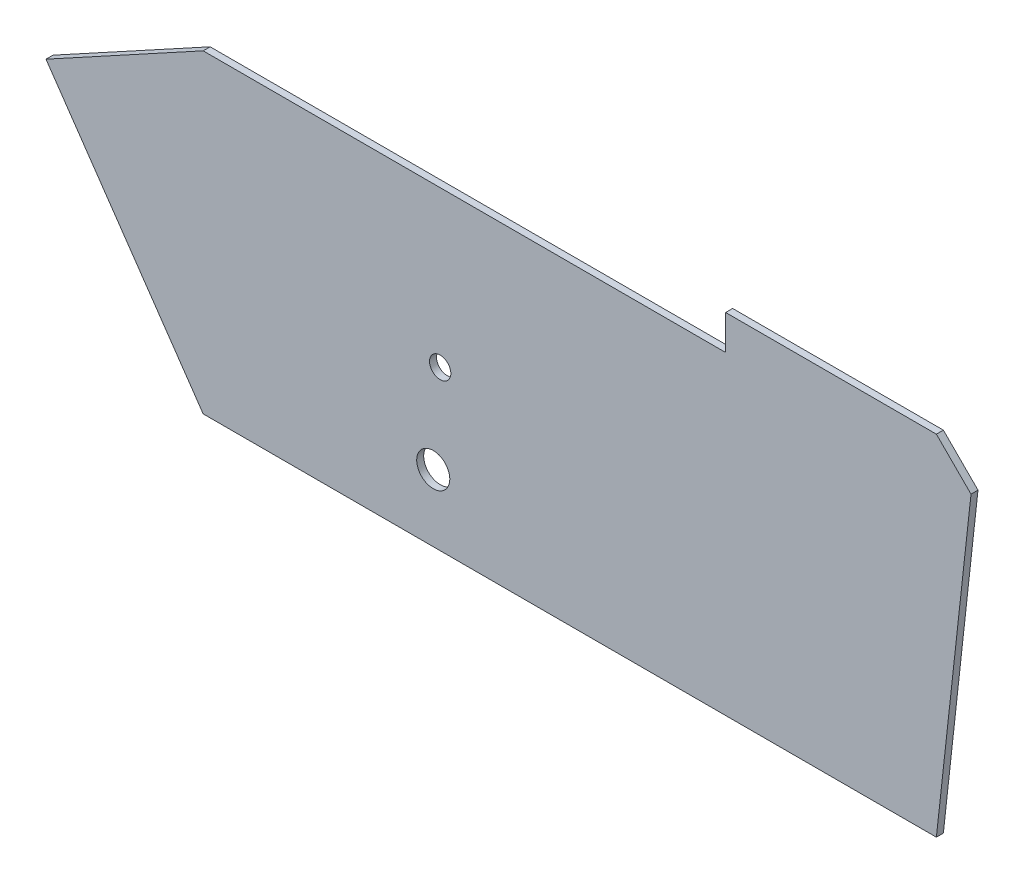
from build123d import *

# Parameters (mm, degrees)
BOSS_EXTRUDE1_DEPTH = 2
SKETCH2_R           = 3.05
SKETCH2_R_2         = 4.740417633
CUT_EXTRUDE1_DEPTH  = 10


with BuildPart() as part:
    # Sketch1 → Boss-Extrude1 (new body)
    with BuildSketch(Plane.XY):
        Polygon((192.039285274, 88.983833718), (201.963048499, 79.060070494), (192.039285274, -11.016166282), (-18.008037477, -11.016166282), (-63.036951501, 54.472600305), (-18.008037477, 79.060070494), (131.67120814, 79.060070494), (131.67120814, 88.983833718), align=None)
    extrude(amount=BOSS_EXTRUDE1_DEPTH)

    # Sketch2 → Cut-Extrude1 (cut)
    with BuildSketch(Plane.XY.offset(2)):
        with Locations((49.886677935, 34.46755227)):
            Circle(SKETCH2_R)
        with Locations((47.903695827, 8.119584274)):
            Circle(SKETCH2_R_2)
    extrude(amount=-CUT_EXTRUDE1_DEPTH, mode=Mode.SUBTRACT)


solid = part.part
